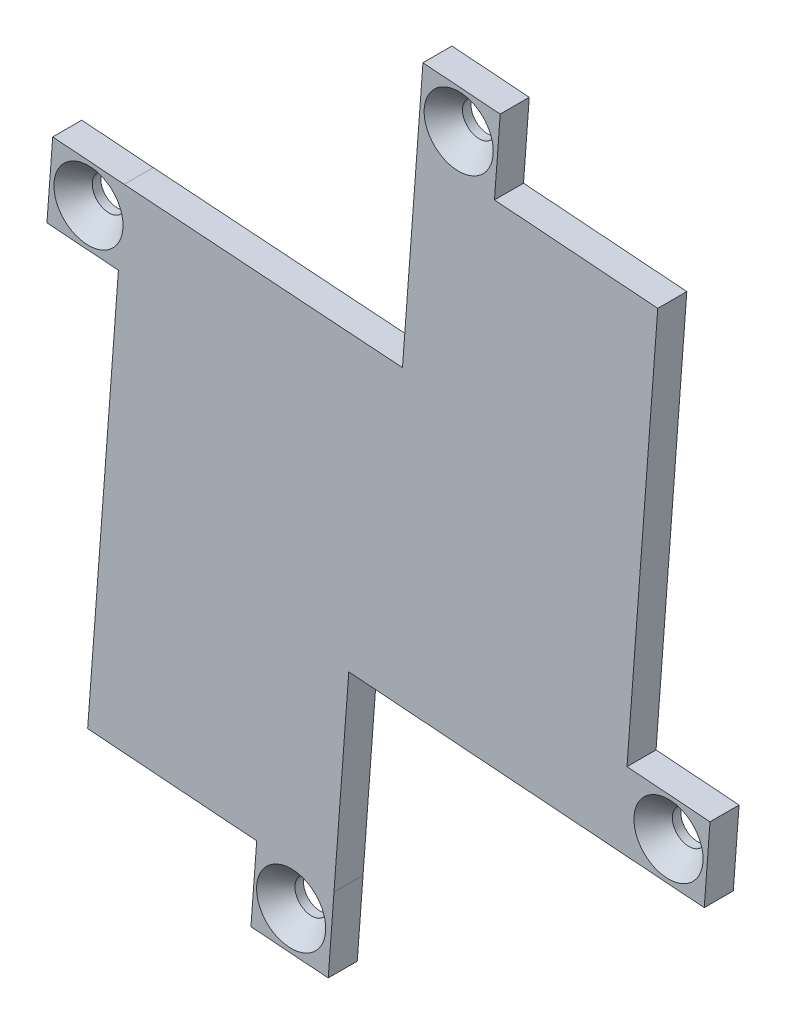
from build123d import *

# Parameters (mm, degrees)
BOSS_EXTRUDE1_DEPTH                           = 3
CSK_FOR_5_FLAT_HEAD_SOCKET_CAP_SCREW1_A_COUNT = 2
CSK_FOR_5_FLAT_HEAD_SOCKET_CAP_SCREW1_A_PITCH = 56.41402705
CSK_FOR_5_FLAT_HEAD_SOCKET_CAP_SCRE_2_COUNT   = 2
CSK_FOR_5_FLAT_HEAD_SOCKET_CAP_SCRE_2_PITCH   = 80.02134109
CSK_FOR_5_FLAT_HEAD_SOCKET_CAP_SCRE_3_COUNT   = 2
CSK_FOR_5_FLAT_HEAD_SOCKET_CAP_SCRE_3_PITCH   = 46.660638534


with BuildPart() as part:
    # Sketch1 → Boss-Extrude1 (new body)
    with BuildSketch(Plane.XY):
        Polygon((-25.209392257, 17.065862145), (-32.589765844, 17.616547994), (-33.185013977, 9.638724086), (-25.804640414, 9.088037903), (-28.980934475, -33.481127138), (-11.529359642, -34.783274677), (-12.124624122, -42.761097701), (-4.146801098, -43.356362181), (-3.551536618, -35.378539157), (-2.025288651, -14.922973048), (34.074511236, -17.616481792), (34.672848055, -17.661125404), (35.268112443, -9.683303605), (26.697352489, -9.043797194), (29.87364655, 33.525367847), (13.014992274, 34.783274677), (13.610256754, 42.761097701), (5.63243373, 43.356362181), (5.03716925, 35.378539157), (3.51996828, 15.044798681), align=None)
    extrude(amount=BOSS_EXTRUDE1_DEPTH)

    # Sketch2 → CSK for #5 Flat Head Socket Cap Screw1 (revolve, cut)
    with BuildSketch(Plane(origin=(-7.973395272, -39.059721921, 3), x_dir=(0, -1, 0), z_dir=(1, 0, 0))):
        Polygon((0, 0), (0, 3), (1.7272, 3), (1.7272, 2.118403422), (3.5687, 0), align=None)
    csk_for_5_flat_head_socket_cap_screw1 = revolve(axis=Axis((-7.973395272, -39.059721921, 9.35), (0, 0, -1)), mode=Mode.SUBTRACT)

    # CSK for #5 Flat Head Socket Cap Screw1 a: CSK for #5 Flat Head Socket Cap Screw1 ×2
    with Locations(*[Vector(-0.370919862, 0.928664878, 0) * (i * CSK_FOR_5_FLAT_HEAD_SOCKET_CAP_SCREW1_A_PITCH) for i in range(1, CSK_FOR_5_FLAT_HEAD_SOCKET_CAP_SCREW1_A_COUNT)]):
        add(csk_for_5_flat_head_socket_cap_screw1, mode=Mode.SUBTRACT)

    # CSK for _5 Flat Head Socket Cap Scre 2: CSK for #5 Flat Head Socket Cap Screw1 ×2
    with Locations(*[Vector(0.216156191, 0.976358797, 0) * (i * CSK_FOR_5_FLAT_HEAD_SOCKET_CAP_SCRE_2_PITCH) for i in range(1, CSK_FOR_5_FLAT_HEAD_SOCKET_CAP_SCRE_2_COUNT)]):
        add(csk_for_5_flat_head_socket_cap_screw1, mode=Mode.SUBTRACT)

    # CSK for _5 Flat Head Socket Cap Scre 3: CSK for #5 Flat Head Socket Cap Screw1 ×2
    with Locations(*[Vector(0.834857059, 0.550466794, 0) * (i * CSK_FOR_5_FLAT_HEAD_SOCKET_CAP_SCRE_3_PITCH) for i in range(1, CSK_FOR_5_FLAT_HEAD_SOCKET_CAP_SCRE_3_COUNT)]):
        add(csk_for_5_flat_head_socket_cap_screw1, mode=Mode.SUBTRACT)


solid = part.part
